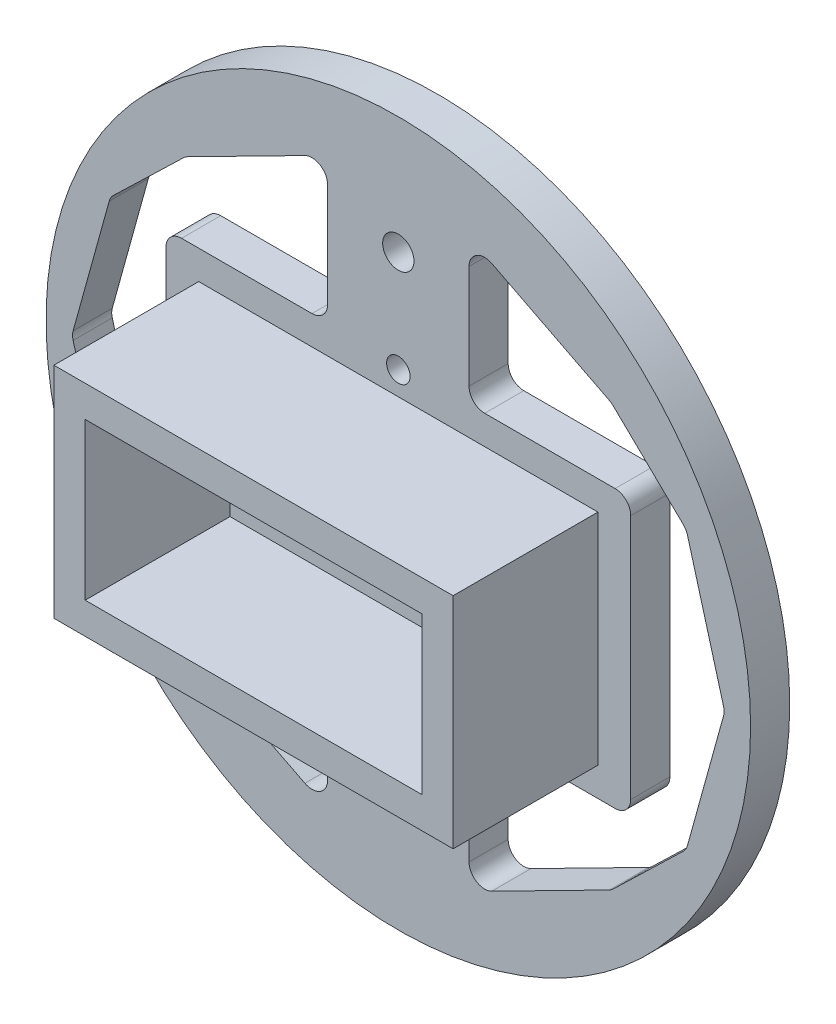
from build123d import *

# Parameters (mm, degrees)
SKETCH1_R           = 45
SKETCH1_R_2         = 2.5
SKETCH1_R_3         = 1.5
BOSS_EXTRUDE1_DEPTH = 5
BOSS_EXTRUDE2_DEPTH = 18.5
SKETCH4_R           = 2
CUT_EXTRUDE1_DEPTH  = 10
CUT_EXTRUDE2_DEPTH  = 10
FILLET1_R           = 2


with BuildPart() as part:
    # Sketch1 → Boss-Extrude1 (new body)
    with BuildSketch(Plane.XY):
        Circle(SKETCH1_R)
        Circle(SKETCH1_R_2, mode=Mode.SUBTRACT)
        with Locations((0, 17)):
            Circle(SKETCH1_R_3, mode=Mode.SUBTRACT)
        with Locations((17, 0)):
            Circle(SKETCH1_R_3, mode=Mode.SUBTRACT)
        with Locations((0, -17)):
            Circle(SKETCH1_R_3, mode=Mode.SUBTRACT)
        with Locations((-17, 0)):
            Circle(SKETCH1_R_3, mode=Mode.SUBTRACT)
    extrude(amount=BOSS_EXTRUDE1_DEPTH)

    # Sketch2 → Boss-Extrude2 (add)
    with BuildSketch(Plane.XY.offset(5)):
        Polygon((-25.5, 10), (-25.5, -10), (-25.5, -14), (0, -14), (0, -10), (-21.5, -10), (-21.5, 10), (0, 10), (0, 14), (-25.5, 14), align=None)
    boss_extrude2 = extrude(amount=BOSS_EXTRUDE2_DEPTH)

    # Mirror1: Boss-Extrude2 across plane
    add(boss_extrude2.mirror(Plane(origin=(0, 0, 0), x_dir=(0, 0, 1), z_dir=(1, 0, 0))))

    # Sketch4 → Cut-Extrude1 (cut)
    with BuildSketch(Plane.XY.offset(5)):
        with Locations((0, 30)):
            Circle(SKETCH4_R)
        with Locations((0, -30)):
            Circle(SKETCH4_R)
    extrude(amount=-CUT_EXTRUDE1_DEPTH, mode=Mode.SUBTRACT)

    # Sketch5 → Cut-Extrude2 (cut)
    with BuildSketch(Plane.XY.offset(5)):
        Polygon((29.689632614, 17.695025445), (29.689632614, 0), (41.689632614, 0), (36.7907688, 17.695025445), (27.214994246, 26.948021081), (9.031781892, 36.201016717), (9.031781892, 17.695025445), align=None)
        Polygon((29.689632614, 0), (29.689632614, -17.695025445), (9.031781892, -17.695025445), (9.031781892, -36.201016717), (27.214994246, -26.948021081), (36.7907688, -17.695025445), (41.689632614, 0), align=None)
        Polygon((-29.689632614, -17.695025445), (-29.689632614, 0), (-41.689632614, 0), (-36.7907688, -17.695025445), (-27.214994246, -26.948021081), (-9.031781892, -36.201016717), (-9.031781892, -17.695025445), align=None)
        Polygon((-29.689632614, 0), (-29.689632614, 17.695025445), (-9.031781892, 17.695025445), (-9.031781892, 36.201016717), (-27.214994246, 26.948021081), (-36.7907688, 17.695025445), (-41.689632614, 0), align=None)
    extrude(amount=-CUT_EXTRUDE2_DEPTH, mode=Mode.SUBTRACT)

    # Fillet1
    fillet1_edges = [part.edges().sort_by_distance(p)[0] for p in [
        (9.031781892, -36.201016717, 2.5),
        (9.031781892, -17.695025445, 2.5),
        (29.689632614, -17.695025445, 2.5),
        (-29.689632614, -17.695025445, 2.5),
        (-9.031781892, -17.695025445, 2.5),
        (-9.031781892, -36.201016717, 2.5),
        (-27.214994246, -26.948021081, 2.5),
        (-36.7907688, -17.695025445, 2.5),
        (-41.689632614, 0, 2.5),
        (-36.7907688, 17.695025445, 2.5),
        (-27.214994246, 26.948021081, 2.5),
        (-9.031781892, 36.201016717, 2.5),
        (-9.031781892, 17.695025445, 2.5),
        (-29.689632614, 17.695025445, 2.5),
        (29.689632614, 17.695025445, 2.5),
        (9.031781892, 17.695025445, 2.5),
        (9.031781892, 36.201016717, 2.5),
        (27.214994246, 26.948021081, 2.5),
        (36.7907688, 17.695025445, 2.5),
        (41.689632614, 0, 2.5),
        (36.7907688, -17.695025445, 2.5),
        (27.214994246, -26.948021081, 2.5),
    ]]
    fillet(fillet1_edges, radius=FILLET1_R)


solid = part.part
